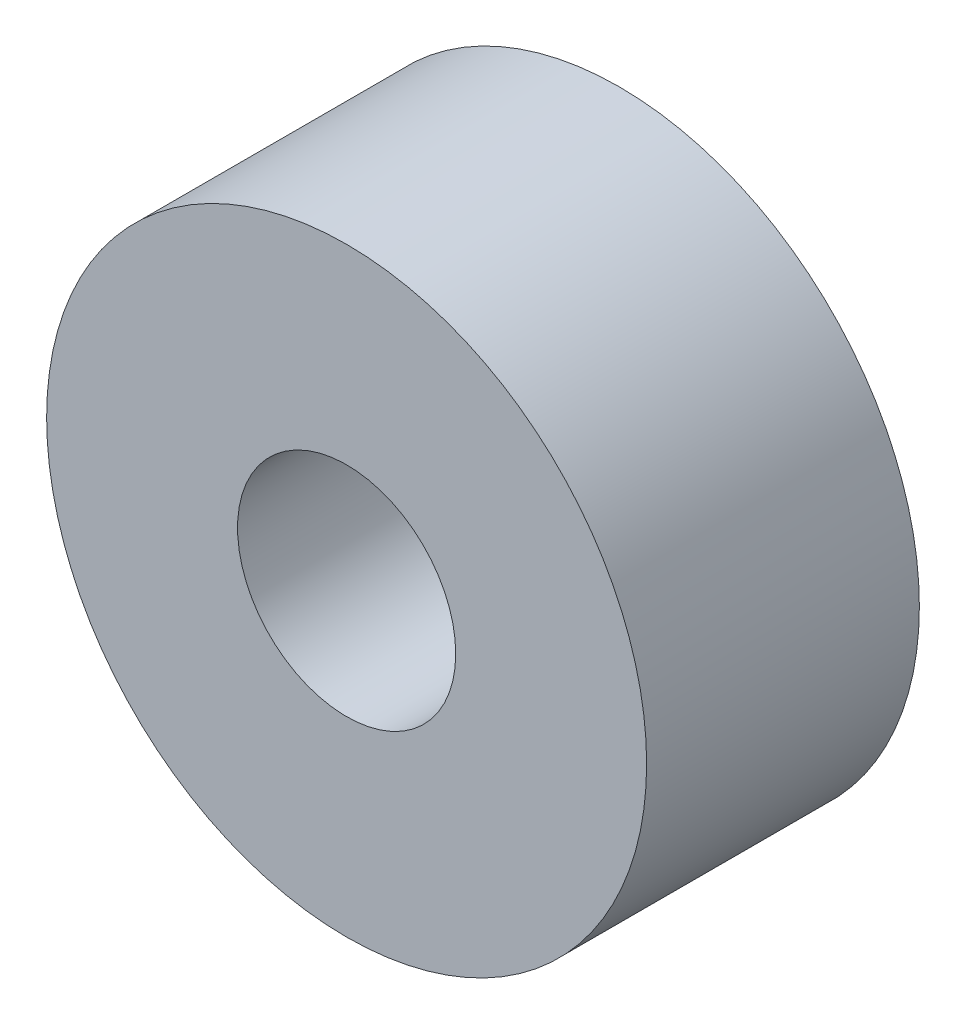
from build123d import *

# Parameters (mm, degrees)
IZIM1_R                     = 11
IZIM1_R_2                   = 4
Y_KSEKLIK_EKSTR_ZYON1_DEPTH = 10


with BuildPart() as part:
    # Çizim1 → Yükseklik-Ekstrüzyon1 (new body)
    with BuildSketch(Plane.XY):
        Circle(IZIM1_R)
        Circle(IZIM1_R_2, mode=Mode.SUBTRACT)
    extrude(amount=Y_KSEKLIK_EKSTR_ZYON1_DEPTH)


solid = part.part
